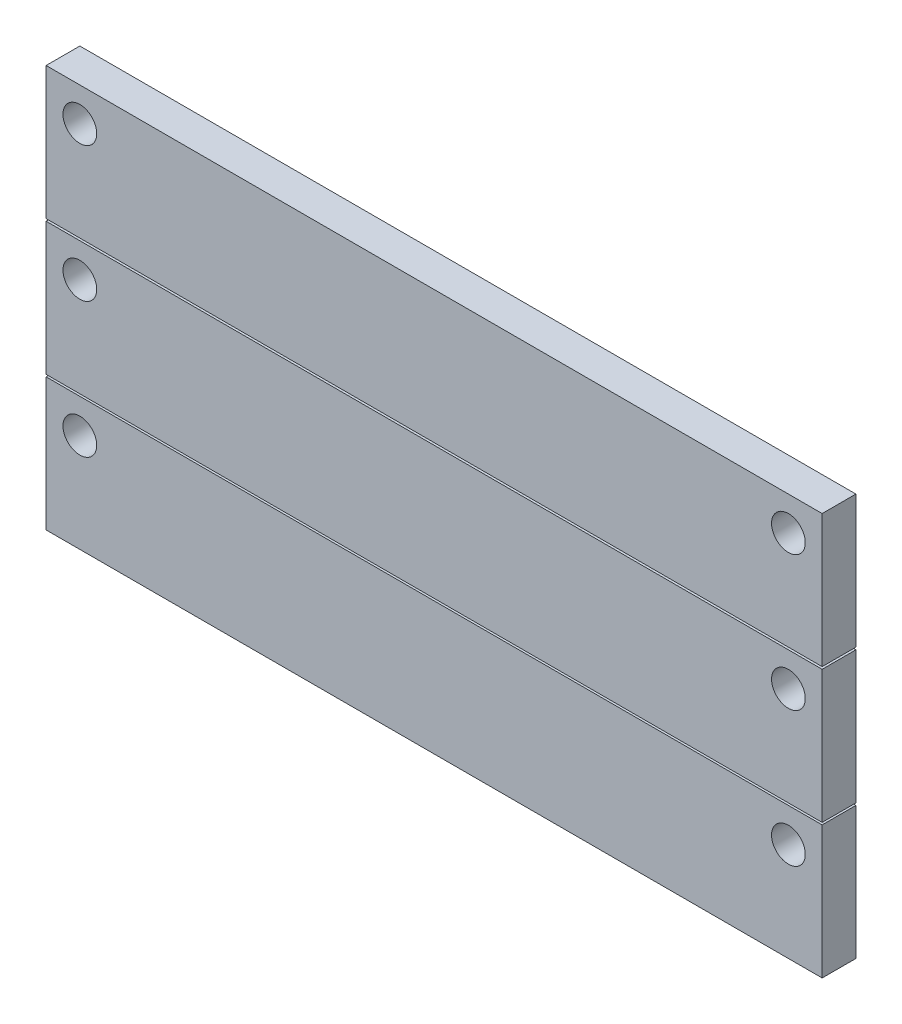
from build123d import *

# Parameters (mm, degrees)
SKETCH1_W             = 584.2
SKETCH1_H             = 99.822
BOSS_EXTRUDE1_DEPTH   = 25.4
BOSS_EXTRUDE1_2_DEPTH = 25.4
BOSS_EXTRUDE1_3_DEPTH = 25.4
SKETCH2_R             = 12.7
CUT_EXTRUDE1_DEPTH    = 26.4
LPATTERN1_COUNT       = 3
LPATTERN1_PITCH       = 101.6


with BuildPart() as part:
    # Sketch1 → Boss-Extrude1 (new body)
    with BuildSketch(Plane.XY):
        with Locations((-292.1, -49.911)):
            Rectangle(SKETCH1_W, SKETCH1_H)
    extrude(amount=BOSS_EXTRUDE1_DEPTH)


with BuildPart() as body_2:
    # Sketch1 → Boss-Extrude1 2 (new body)
    with BuildSketch(Plane.XY):
        with Locations((-292.1, 51.628691072)):
            Rectangle(SKETCH1_W, SKETCH1_H)
    extrude(amount=BOSS_EXTRUDE1_2_DEPTH)

    # Sketch2 → Cut-Extrude1 (cut, through all)
    with BuildSketch(Plane.XY.offset(25.4)):
        with Locations((-558.8, 76.139691072)):
            Circle(SKETCH2_R)
        with Locations((-25.4, 76.139691072)):
            Circle(SKETCH2_R)
    cut_extrude1 = extrude(amount=-CUT_EXTRUDE1_DEPTH, mode=Mode.SUBTRACT)


with BuildPart() as body_3:
    # Sketch1 → Boss-Extrude1 3 (new body)
    with BuildSketch(Plane.XY):
        with Locations((-292.1, -151.356836193)):
            Rectangle(SKETCH1_W, SKETCH1_H)
    extrude(amount=BOSS_EXTRUDE1_3_DEPTH)


with BuildPart() as lpattern1_tool:
    # LPattern1: Cut-Extrude1 ×3
    with Locations(*[(0, -i * LPATTERN1_PITCH, 0) for i in range(1, LPATTERN1_COUNT)]):
        add(cut_extrude1)


with BuildPart() as part_1:
    add(part.part)

    # LPattern1: cut by lpattern1_tool
    add(lpattern1_tool.part, mode=Mode.SUBTRACT)


with BuildPart() as body_3_1:
    add(body_3.part)

    # LPattern1: cut by lpattern1_tool
    add(lpattern1_tool.part, mode=Mode.SUBTRACT)


solid = Compound([body_2.part, part_1.part, body_3_1.part])
